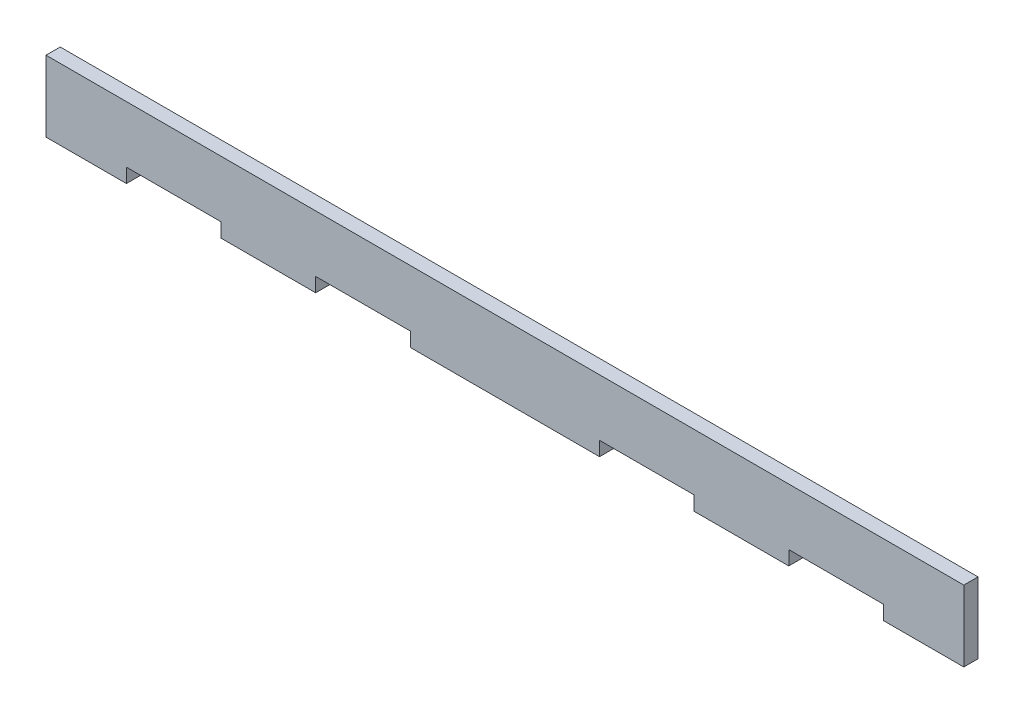
from build123d import *

# Parameters (mm, degrees)
SKETCH1_W           = 200
SKETCH1_H           = 15
BOSS_EXTRUDE1_DEPTH = 3
SKETCH2_W           = 20
SKETCH2_H           = 3
SKETCH2_W_2         = 3
SKETCH2_H_2         = 15
CUT_EXTRUDE2_DEPTH  = 3


with BuildPart() as part:
    # Sketch1 → Boss-Extrude1 (new body)
    with BuildSketch(Plane.XY):
        Rectangle(SKETCH1_W, SKETCH1_H)
    extrude(amount=BOSS_EXTRUDE1_DEPTH)

    # Sketch2 → Cut-Extrude2 (cut)
    with BuildSketch(Plane.XY.offset(3)):
        with Locations((-70, -6)):
            Rectangle(SKETCH2_W, SKETCH2_H)
        with Locations((98.5, 0)):
            Rectangle(SKETCH2_W_2, SKETCH2_H_2)
        with Locations((-98.5, 0)):
            Rectangle(SKETCH2_W_2, SKETCH2_H_2)
        with Locations((-30, -6)):
            Rectangle(SKETCH2_W, SKETCH2_H)
        with Locations((30, -6)):
            Rectangle(SKETCH2_W, SKETCH2_H)
        with Locations((70, -6)):
            Rectangle(SKETCH2_W, SKETCH2_H)
    extrude(amount=-CUT_EXTRUDE2_DEPTH, mode=Mode.SUBTRACT)


solid = part.part
